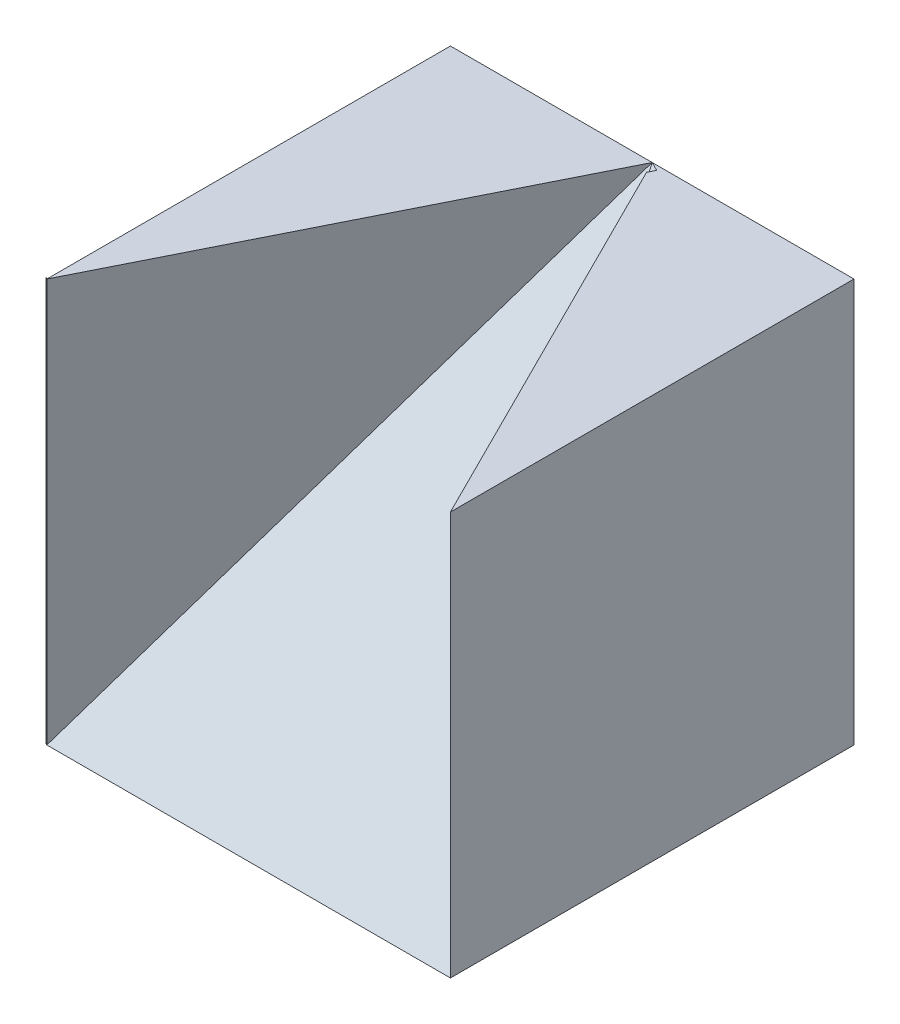
from build123d import *

# Parameters (mm, degrees)
SKETCH1_W           = 40
SKETCH1_H           = 40
BOSS_EXTRUDE1_DEPTH = 40
CUT_EXTRUDE1_DEPTH  = 40
CUT_EXTRUDE3_DEPTH  = 40
CUT_EXTRUDE5_DEPTH  = 1
BOSS_EXTRUDE2_DEPTH = 26
CUT_EXTRUDE7_DEPTH  = 5
CUT_EXTRUDE8_DEPTH  = 5
CUT_EXTRUDE9_DEPTH  = 5
SKETCH10_W          = 40
SKETCH10_H          = 40
CUT_EXTRUDE10_DEPTH = 50
SKETCH11_W          = 56.739460666
SKETCH11_H          = 49.026259181
CUT_EXTRUDE11_DEPTH = 50


with BuildPart() as part:
    # Sketch1 → Boss-Extrude1 (new body)
    with BuildSketch(Plane.XY):
        with Locations((20, 20)):
            Rectangle(SKETCH1_W, SKETCH1_H)
    extrude(amount=BOSS_EXTRUDE1_DEPTH)

    # Sketch2 → Cut-Extrude1 (cut)
    with BuildSketch(Plane(origin=(0, 20, 20), x_dir=(1, 0, 0), z_dir=(0, 0.707106781, 0.707106781))):
        Polygon((40, -28.284271247), (0, -28.284271247), (20, 28.284271247), align=None)
    extrude(amount=CUT_EXTRUDE1_DEPTH, mode=Mode.SUBTRACT)

    # Sketch4 → Cut-Extrude3 (cut)
    with BuildSketch(Plane(origin=(16, 0, -8), x_dir=(0.447213595, 0, 0.894427191), z_dir=(-0.894427191, 0, 0.447213595))):
        Polygon((8.94427191, 40), (53.66563146, 40), (53.66563146, 0), align=None)
    extrude(amount=CUT_EXTRUDE3_DEPTH, mode=Mode.SUBTRACT)

    # Sketch5 → Cut-Extrude5 (cut)
    with BuildSketch(Plane(origin=(16, 0, 8), x_dir=(-0.447213595, 0, 0.894427191), z_dir=(-0.894427191, 0, -0.447213595))):
        Polygon((35.77708764, 0), (-8.94427191, 40), (29.348133104, 45.420073385), align=None)
    extrude(amount=-CUT_EXTRUDE5_DEPTH, mode=Mode.SUBTRACT)

    # Sketch6 → Boss-Extrude2 (add)
    with BuildSketch(Plane(origin=(16, 0, 8), x_dir=(-0.447213595, 0, 0.894427191), z_dir=(-0.894427191, 0, -0.447213595))):
        Polygon((35.77708764, 40), (35.77708764, 0), (-8.94427191, 40), align=None)
    extrude(amount=BOSS_EXTRUDE2_DEPTH)

    # Sketch7 → Cut-Extrude7 (cut)
    with BuildSketch(Plane(origin=(16, 0, 8), x_dir=(0.447213595, 0, -0.894427191), z_dir=(0.894427191, 0, 0.447213595))):
        Polygon((2.978893099, 34.664402987), (-35.77708764, 31.206354084), (-35.77708764, 16), (-33.326207642, 17.315280227), (-35.77708764, 0), align=None)
    extrude(amount=CUT_EXTRUDE7_DEPTH, mode=Mode.SUBTRACT)

    # Sketch8 → Cut-Extrude8 (cut)
    with BuildSketch(Plane(origin=(-15.685739325, 4.964580059, 31.37147865), x_dir=(-0.896620465, -0.069212396, -0.437357275), z_dir=(0.442799889, -0.140147395, -0.885599778))):
        Polygon((-21.749837593, 8.458308195), (-18.716733371, 11.192845531), (-17.494290991, -6.252250535), align=None)
    extrude(amount=-CUT_EXTRUDE8_DEPTH, mode=Mode.SUBTRACT)

    # Sketch9 → Cut-Extrude9 (cut)
    with BuildSketch(Plane(origin=(15.970902322, -3.85667421, 8.59577521), x_dir=(-0.450614766, 0.108815038, 0.88606186), z_dir=(-0.86130493, 0.207989032, -0.463567018))):
        Polygon((35.4424744, 15.010038766), (34.947973708, 15.305740233), (35.4424744, 0), align=None)
    extrude(amount=-CUT_EXTRUDE9_DEPTH, mode=Mode.SUBTRACT)

    # Sketch10 → Cut-Extrude10 (cut)
    with BuildSketch(Plane(origin=(0, 0, 0), x_dir=(-1, 0, 0), z_dir=(0, 0, -1))):
        with Locations((-20, 20)):
            Rectangle(SKETCH10_W, SKETCH10_H)
    extrude(amount=CUT_EXTRUDE10_DEPTH, mode=Mode.SUBTRACT)

    # Sketch11 → Cut-Extrude11 (cut)
    with BuildSketch(Plane.ZY):
        with Locations((11.546622416, 24.513129591)):
            Rectangle(SKETCH11_W, SKETCH11_H)
    extrude(amount=CUT_EXTRUDE11_DEPTH, mode=Mode.SUBTRACT)


solid = part.part
